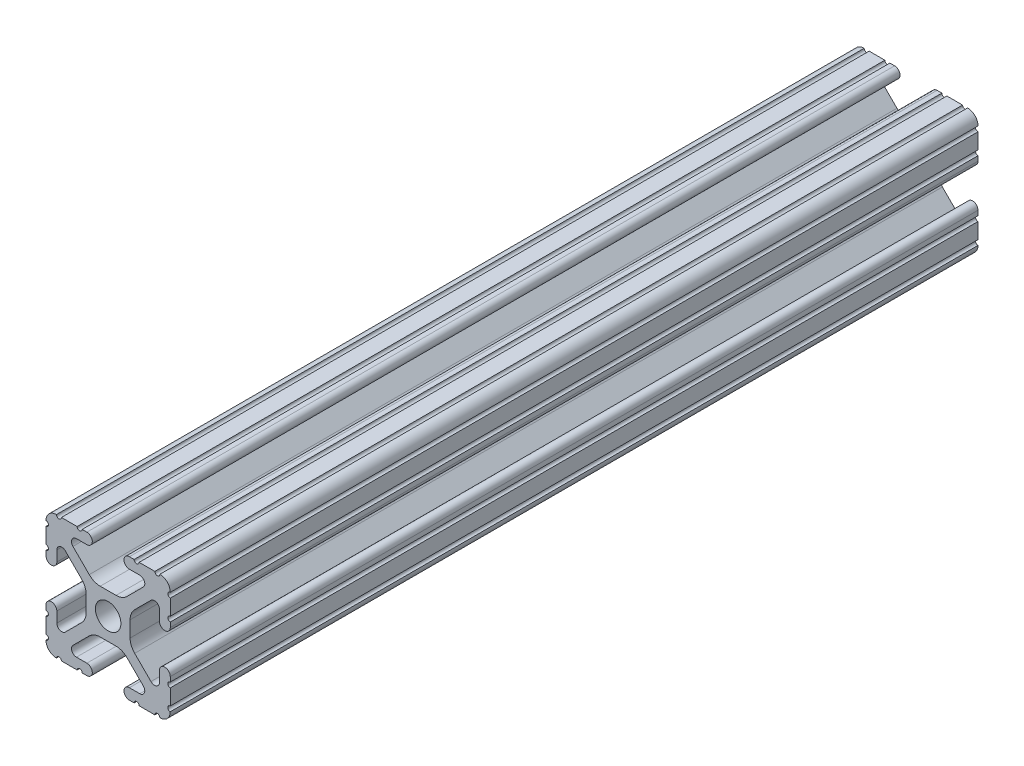
from build123d import *

# Parameters (mm, degrees)
SKETCH1_R           = 2.6035
BOSS_EXTRUDE1_DEPTH = 82.55


with BuildPart() as part:
    # Sketch1 → Boss-Extrude1 (new body, symmetric)
    with BuildSketch(Plane(origin=(0, 0, -450.85), x_dir=(-1, 0, 0), z_dir=(0, 0, -1))):
        with BuildLine():
            Line((12.7, -9.5504), (12.7, -6.3330836))
            ThreePointArc((12.7, -6.3330836), (12.192, -5.8250836), (12.7, -5.3170836))
            Line((12.7, -5.3170836), (12.7, -4.3434))
            ThreePointArc((12.7, -4.3434), (11.5951, -3.2385), (10.4902, -4.3434))
            Line((10.4902, -4.3434), (10.4902, -6.474794456))
            ThreePointArc((10.4902, -6.474794456), (9.863006367, -7.413456061), (8.75577951, -7.193214945))
            Line((8.75577951, -7.193214945), (5.42573597, -3.863171405))
            ThreePointArc((5.42573597, -3.863171405), (4.737482484, -2.833127272), (4.4958, -1.618107374))
            Line((4.4958, -1.618107374), (4.4958, 1.618107374))
            ThreePointArc((4.4958, 1.618107374), (4.737482484, 2.833127272), (5.42573597, 3.863171405))
            Line((5.42573597, 3.863171405), (8.75577951, 7.193214945))
            ThreePointArc((8.75577951, 7.193214945), (9.863006367, 7.413456061), (10.4902, 6.474794456))
            Line((10.4902, 6.474794456), (10.4902, 4.343399971))
            ThreePointArc((10.4902, 4.343399971), (11.5951, 3.238499971), (12.7, 4.343399971))
            Line((12.7, 4.343399971), (12.7, 5.3170836))
            ThreePointArc((12.7, 5.3170836), (12.192, 5.8250836), (12.7, 6.3330836))
            Line((12.7, 6.3330836), (12.7, 9.5504))
            ThreePointArc((12.7, 9.5504), (12.192000006, 10.058323491), (12.699846982, 10.566399977))
            ThreePointArc((12.699846982, 10.566399977), (12.082522516, 12.082522516), (10.566399977, 12.699846982))
            ThreePointArc((10.566399977, 12.699846982), (10.058323491, 12.192000006), (9.5504, 12.7))
            Line((9.5504, 12.7), (6.3330836, 12.7))
            ThreePointArc((6.3330836, 12.7), (5.8250836, 12.192), (5.3170836, 12.7))
            Line((5.3170836, 12.7), (4.3434, 12.7))
            ThreePointArc((4.3434, 12.7), (3.2385, 11.5951), (4.3434, 10.4902))
            Line((4.3434, 10.4902), (6.474794456, 10.4902))
            ThreePointArc((6.474794456, 10.4902), (7.413456061, 9.863006367), (7.193214945, 8.75577951))
            Line((7.193214945, 8.75577951), (3.863171405, 5.42573597))
            ThreePointArc((3.863171405, 5.42573597), (2.833127272, 4.737482484), (1.618107374, 4.4958))
            Line((1.618107374, 4.4958), (-1.618107374, 4.4958))
            ThreePointArc((-1.618107374, 4.4958), (-2.833127272, 4.737482484), (-3.863171405, 5.42573597))
            Line((-3.863171405, 5.42573597), (-7.193214945, 8.75577951))
            ThreePointArc((-7.193214945, 8.75577951), (-7.413456061, 9.863006367), (-6.474794456, 10.4902))
            Line((-6.474794456, 10.4902), (-4.343399971, 10.4902))
            ThreePointArc((-4.343399971, 10.4902), (-3.238499971, 11.5951), (-4.343399971, 12.7))
            Line((-4.343399971, 12.7), (-5.3170836, 12.7))
            ThreePointArc((-5.3170836, 12.7), (-5.8250836, 12.192), (-6.3330836, 12.7))
            Line((-6.3330836, 12.7), (-9.5504, 12.7))
            ThreePointArc((-9.5504, 12.7), (-10.058323491, 12.192000006), (-10.566399977, 12.699846982))
            ThreePointArc((-10.566399977, 12.699846982), (-12.082522516, 12.082522516), (-12.699846982, 10.566399977))
            ThreePointArc((-12.699846982, 10.566399977), (-12.192000006, 10.058323491), (-12.7, 9.5504))
            Line((-12.7, 9.5504), (-12.7, 6.3330836))
            ThreePointArc((-12.7, 6.3330836), (-12.192, 5.8250836), (-12.7, 5.3170836))
            Line((-12.7, 5.3170836), (-12.7, 4.3434))
            ThreePointArc((-12.7, 4.3434), (-11.5951, 3.2385), (-10.4902, 4.3434))
            Line((-10.4902, 4.3434), (-10.4902, 6.474794456))
            ThreePointArc((-10.4902, 6.474794456), (-9.863006367, 7.413456061), (-8.75577951, 7.193214945))
            Line((-8.75577951, 7.193214945), (-5.42573597, 3.863171405))
            ThreePointArc((-5.42573597, 3.863171405), (-4.737482484, 2.833127272), (-4.4958, 1.618107374))
            Line((-4.4958, 1.618107374), (-4.4958, -1.618107374))
            ThreePointArc((-4.4958, -1.618107374), (-4.737482484, -2.833127272), (-5.42573597, -3.863171405))
            Line((-5.42573597, -3.863171405), (-8.75577951, -7.193214945))
            ThreePointArc((-8.75577951, -7.193214945), (-9.863006367, -7.413456061), (-10.4902, -6.474794456))
            Line((-10.4902, -6.474794456), (-10.4902, -4.343399971))
            ThreePointArc((-10.4902, -4.343399971), (-11.5951, -3.238499971), (-12.7, -4.343399971))
            Line((-12.7, -4.343399971), (-12.7, -5.3170836))
            ThreePointArc((-12.7, -5.3170836), (-12.192, -5.8250836), (-12.7, -6.3330836))
            Line((-12.7, -6.3330836), (-12.7, -9.5504))
            ThreePointArc((-12.7, -9.5504), (-12.192000006, -10.058323491), (-12.699846982, -10.566399977))
            ThreePointArc((-12.699846982, -10.566399977), (-12.082522516, -12.082522516), (-10.566399977, -12.699846982))
            ThreePointArc((-10.566399977, -12.699846982), (-10.058323491, -12.192000006), (-9.5504, -12.7))
            Line((-9.5504, -12.7), (-6.3330836, -12.7))
            ThreePointArc((-6.3330836, -12.7), (-5.8250836, -12.192), (-5.3170836, -12.7))
            Line((-5.3170836, -12.7), (-4.3434, -12.7))
            ThreePointArc((-4.3434, -12.7), (-3.2385, -11.5951), (-4.3434, -10.4902))
            Line((-4.3434, -10.4902), (-6.474794456, -10.4902))
            ThreePointArc((-6.474794456, -10.4902), (-7.413456061, -9.863006367), (-7.193214945, -8.75577951))
            Line((-7.193214945, -8.75577951), (-3.863171405, -5.42573597))
            ThreePointArc((-3.863171405, -5.42573597), (-2.833127272, -4.737482484), (-1.618107374, -4.4958))
            Line((-1.618107374, -4.4958), (1.618107374, -4.4958))
            ThreePointArc((1.618107374, -4.4958), (2.833127272, -4.737482484), (3.863171405, -5.42573597))
            Line((3.863171405, -5.42573597), (7.193214945, -8.75577951))
            ThreePointArc((7.193214945, -8.75577951), (7.413456061, -9.863006367), (6.474794456, -10.4902))
            Line((6.474794456, -10.4902), (4.343399971, -10.4902))
            ThreePointArc((4.343399971, -10.4902), (3.238499971, -11.5951), (4.343399971, -12.7))
            Line((4.343399971, -12.7), (5.3170836, -12.7))
            ThreePointArc((5.3170836, -12.7), (5.8250836, -12.192), (6.3330836, -12.7))
            Line((6.3330836, -12.7), (9.5504, -12.7))
            ThreePointArc((9.5504, -12.7), (10.058323491, -12.192000006), (10.566399977, -12.699846982))
            ThreePointArc((10.566399977, -12.699846982), (12.082522516, -12.082522516), (12.699846982, -10.566399977))
            ThreePointArc((12.699846982, -10.566399977), (12.192000006, -10.058323491), (12.7, -9.5504))
        make_face()
        Circle(SKETCH1_R, mode=Mode.SUBTRACT)
    extrude(amount=BOSS_EXTRUDE1_DEPTH, both=True)


solid = part.part
